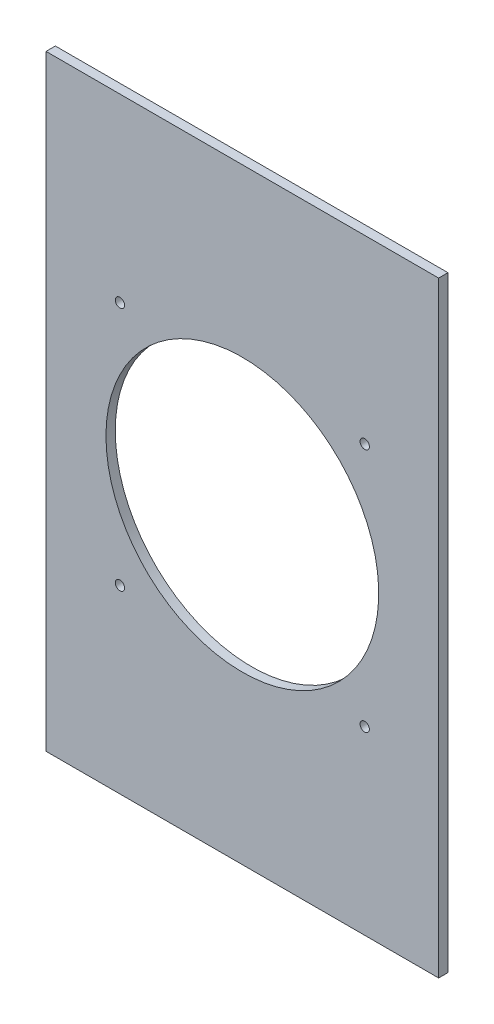
from build123d import *

# Parameters (mm, degrees)
SKETCH1_W          = 168.4
SKETCH1_H          = 260
EXTRUDE1_DEPTH     = 4
SKETCH2_R          = 58.5
SKETCH2_R_2        = 2
CUT_EXTRUDE5_DEPTH = 4


with BuildPart() as part:
    # Sketch1 → Extrude1 (new body)
    with BuildSketch(Plane.XY):
        Rectangle(SKETCH1_W, SKETCH1_H)
    extrude(amount=EXTRUDE1_DEPTH)

    # Sketch2 → Cut-Extrude5 (cut)
    with BuildSketch(Plane.XY):
        Circle(SKETCH2_R)
        with Locations((-52.5, -52.5)):
            Circle(SKETCH2_R_2)
        with Locations((52.5, -52.5)):
            Circle(SKETCH2_R_2)
        with Locations((52.5, 52.5)):
            Circle(SKETCH2_R_2)
        with Locations((-52.5, 52.5)):
            Circle(SKETCH2_R_2)
    extrude(amount=CUT_EXTRUDE5_DEPTH, mode=Mode.SUBTRACT)


solid = part.part
